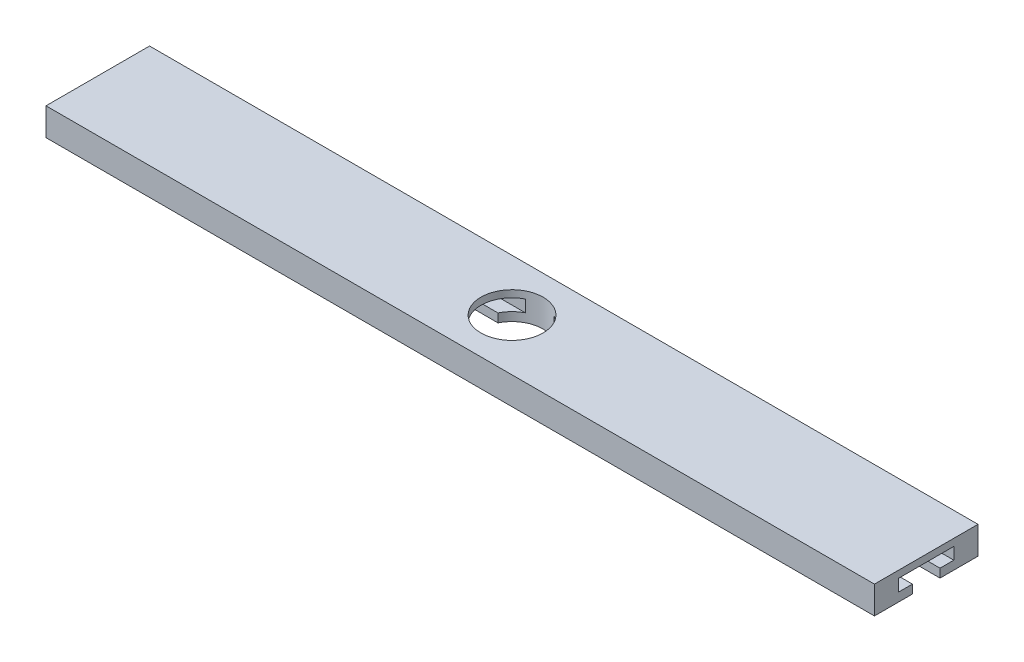
from build123d import *

# Parameters (mm, degrees)
SKETCH1_W               = 120
SKETCH1_H               = 4
BOSS_EXTRUDE1_DEPTH     = 15
CUT_EXTRUDE1_DEPTH      = 27
CUT_EXTRUDE1_DEPTH_BACK = 130
SKETCH4_R               = 4.5
CUT_EXTRUDE2_DEPTH      = 44


with BuildPart() as part:
    # Sketch1 → Boss-Extrude1 (new body)
    with BuildSketch(Plane.XY):
        with Locations((-39.26849149, 32.447485816)):
            Rectangle(SKETCH1_W, SKETCH1_H)
    extrude(amount=BOSS_EXTRUDE1_DEPTH)

    # Sketch3 → Cut-Extrude1 (cut, two sides)
    with BuildSketch(Plane(origin=(0, 0, 0), x_dir=(0, 0, -1), z_dir=(1, 0, 0))) as cut_extrude1_sk:
        Polygon((-9.5, 30.447485816), (-5.5, 30.447485816), (-5.5, 31.699233238), (-3.5, 31.699233238), (-3.5, 33.429568038), (-11.5, 33.429568038), (-11.5, 31.699233238), (-9.5, 31.699233238), align=None)
    extrude(amount=CUT_EXTRUDE1_DEPTH, mode=Mode.SUBTRACT)
    extrude(cut_extrude1_sk.sketch, amount=-CUT_EXTRUDE1_DEPTH_BACK, mode=Mode.SUBTRACT)

    # Sketch4 → Cut-Extrude2 (cut)
    with BuildSketch(Plane(origin=(0, 0, 0), x_dir=(1, 0, 0), z_dir=(0, 1, 0))):
        with Locations((-39.26849149, -7.5)):
            Circle(SKETCH4_R)
    extrude(amount=CUT_EXTRUDE2_DEPTH, mode=Mode.SUBTRACT)


solid = part.part
